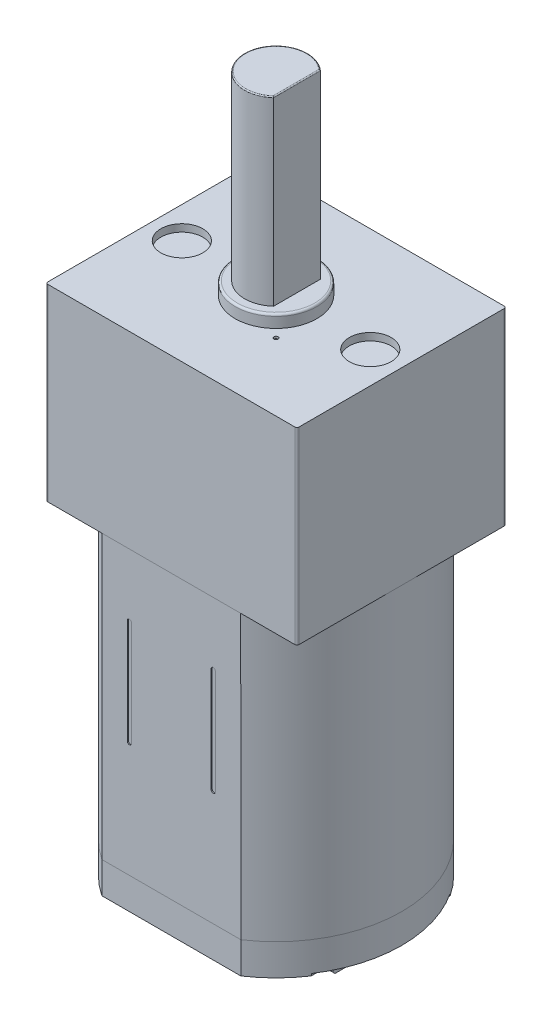
from build123d import *

# Parameters (mm, degrees)
EXTRUDE_1_DEPTH     = 13.5
SKETCH_2_W          = 12
SKETCH_2_H          = 10
EXTRUDE_2_DEPTH     = 9
SKETCH_3_R          = 1.95
EXTRUDE_3_DEPTH     = 0.6
EXTRUDE_4_DEPTH     = 8.67
SKETCH_5_R          = 1
CUT_EXTRUDE_1_DEPTH = 0.35
FILLET_1_R          = 0.1
EXTRUDE_6_DEPTH     = 1.4
EXTRUDE_7_DEPTH     = 0.1
SKETCH_8_W          = 0.3
SKETCH_8_H          = 1.5
EXTRUDE_8_DEPTH     = 2
CHAMFER_1_SIZE      = 0.1
SKETCH_9_R          = 0.4
CUT_EXTRUDE_2_DEPTH = 7
SKETCH_10_R         = 2.5
EXTRUDE_9_DEPTH     = 2
FILLET_2_R          = 0.2
SKETCH_11_R         = 0.1
CUT_EXTRUDE_3_DEPTH = 0.7
FILLET_3_R          = 0.1
CUT_EXTRUDE_4_DEPTH = 0.05
FILLET_4_R          = 0.05
FILLET_5_R          = 0.1


with BuildPart() as part:
    # Эскиз1 → Бобышка-Вытянуть1 (new body)
    with BuildSketch(Plane(origin=(0, 0, 0), x_dir=(1, 0, 0), z_dir=(0, 1, 0))):
        with BuildLine():
            Line((-3.31662479, 5), (3.31662479, 5))
            ThreePointArc((3.31662479, 5), (6, 0), (3.31662479, -5))
            Line((3.31662479, -5), (-3.31662479, -5))
            ThreePointArc((-3.31662479, -5), (-6, 0), (-3.31662479, 5))
        make_face()
    extrude(amount=EXTRUDE_1_DEPTH)

    # Эскиз2 → Бобышка-Вытянуть2 (add)
    with BuildSketch(Plane(origin=(0, 13.5, 0), x_dir=(1, 0, 0), z_dir=(0, 1, 0))):
        with Locations((0, -0.001677367)):
            Rectangle(SKETCH_2_W, SKETCH_2_H)
    extrude(amount=EXTRUDE_2_DEPTH)

    # Эскиз3 → Бобышка-Вытянуть3 (add)
    with BuildSketch(Plane(origin=(0, 22.5, 0), x_dir=(1, 0, 0), z_dir=(0, 1, 0))):
        with Locations(Location((0, 0, 0), (0, 0, 270))):
            Circle(SKETCH_3_R)
    extrude(amount=EXTRUDE_3_DEPTH)

    # Эскиз4 → Бобышка-Вытянуть4 (add)
    with BuildSketch(Plane(origin=(0, 23.1, 0), x_dir=(1, 0, 0), z_dir=(0, 1, 0))):
        with BuildLine():
            Line((1, 1.118033989), (1, -1.118033989))
            ThreePointArc((1, -1.118033989), (-1.5, 0), (1, 1.118033989))
        make_face()
    extrude(amount=EXTRUDE_4_DEPTH)

    # Эскиз5 → Вырез-Вытянуть1 (cut)
    with BuildSketch(Plane(origin=(0, 22.5, 0), x_dir=(1, 0, 0), z_dir=(0, 1, 0))):
        with Locations(Location((-4.5, 0, 0), (0, 0, 270))):
            Circle(SKETCH_5_R)
        with Locations(Location((4.5, 0, 0), (0, 0, 90))):
            Circle(SKETCH_5_R)
    extrude(amount=-CUT_EXTRUDE_1_DEPTH, mode=Mode.SUBTRACT)

    # Скругление1
    fillet_1_edges = [part.edges().sort_by_distance(p)[0] for p in [
        (-6, 18, 5.001677367),
        (6, 18, 5.001677367),
        (6, 18, -4.998322633),
        (-6, 18, -4.998322633),
    ]]
    fillet(fillet_1_edges, radius=FILLET_1_R)

    # Эскиз11 → Вырез-Вытянуть3 (cut)
    with BuildSketch(Plane(origin=(0, 23.1, 0), x_dir=(1, 0, 0), z_dir=(0, 1, 0))):
        with Locations(Location((1.767766953, -1.767766953, 0), (0, 0, 270))):
            Circle(SKETCH_11_R)
        with Locations(Location((-1.767766953, 1.767766953, 0), (0, 0, 270))):
            Circle(SKETCH_11_R)
    extrude(amount=-CUT_EXTRUDE_3_DEPTH, mode=Mode.SUBTRACT)

    # Эскиз12 → Вырез-Вытянуть4 (cut)
    with BuildSketch(Plane(origin=(0, 0, -5), x_dir=(-1, 0, 0), z_dir=(0, 0, -1))):
        with BuildLine():
            Line((1.9, 5.5), (1.9, 10.5))
            ThreePointArc((1.9, 10.5), (2, 10.6), (2.1, 10.5))
            Line((2.1, 10.5), (2.1, 5.5))
            ThreePointArc((2.1, 5.5), (2, 5.4), (1.9, 5.5))
        make_face()
        with BuildLine():
            Line((-2.1, 5.5), (-2.1, 10.5))
            ThreePointArc((-2.1, 10.5), (-2, 10.6), (-1.9, 10.5))
            Line((-1.9, 10.5), (-1.9, 5.5))
            ThreePointArc((-1.9, 5.5), (-2, 5.4), (-2.1, 5.5))
        make_face()
    cut_extrude_4 = extrude(amount=-CUT_EXTRUDE_4_DEPTH, mode=Mode.SUBTRACT)

    # Зеркальное отражение1: Вырез-Вытянуть4 across plane
    add(cut_extrude_4.mirror(Plane(origin=(0, 0, 0), x_dir=(1, 0, 0), z_dir=(0, 0, -1))), mode=Mode.SUBTRACT)

    # Скругление4
    fillet_4_edges = [part.edges().sort_by_distance(p)[0] for p in [
        (-1.5, 31.77, 0),
        (1, 31.77, 0),
    ]]
    fillet(fillet_4_edges, radius=FILLET_4_R)

    # Скругление5
    fillet_5_edges = [part.edges().sort_by_distance(p)[0] for p in [
        (0, 23.1, -1.95),
    ]]
    fillet(fillet_5_edges, radius=FILLET_5_R)


with BuildPart() as body_2:
    # Эскиз6 → Бобышка-Вытянуть6 (new body)
    with BuildSketch(Plane.XZ):
        with BuildLine():
            Line((-3.31662479, -5), (3.31662479, -5))
            ThreePointArc((3.31662479, -5), (6, 0), (3.31662479, 5))
            Line((3.31662479, 5), (-3.31662479, 5))
            ThreePointArc((-3.31662479, 5), (-6, 0), (-3.31662479, -5))
        make_face()
    extrude(amount=EXTRUDE_6_DEPTH)

    # Эскиз7 → Бобышка-Вытянуть7 (add)
    with BuildSketch(Plane(origin=(0, -1.4, 0), x_dir=(-1, 0, 0), z_dir=(0, -1, 0))):
        with BuildLine():
            ThreePointArc((3.31662479, -5), (4.242640687, -4.242640687), (5, -3.31662479))
            Line((5, -3.31662479), (5, 3.31662479))
            ThreePointArc((5, 3.31662479), (4.242640687, 4.242640687), (3.31662479, 5))
            Line((3.31662479, 5), (-3.31662479, 5))
            ThreePointArc((-3.31662479, 5), (-4.242640687, 4.242640687), (-5, 3.31662479))
            Line((-5, 3.31662479), (-5, -3.31662479))
            ThreePointArc((-5, -3.31662479), (-4.242640687, -4.242640687), (-3.31662479, -5))
            Line((-3.31662479, -5), (3.31662479, -5))
        make_face()
    extrude(amount=EXTRUDE_7_DEPTH)

    # Эскиз8 → Бобышка-Вытянуть8 (add)
    with BuildSketch(Plane(origin=(0, -1.5, 0), x_dir=(-1, 0, 0), z_dir=(0, -1, 0))):
        with Locations((3.315, 0)):
            Rectangle(SKETCH_8_W, SKETCH_8_H)
        with Locations((-3.315, 0)):
            Rectangle(SKETCH_8_W, SKETCH_8_H)
    extrude(amount=EXTRUDE_8_DEPTH)

    # Фаска1
    chamfer_1_edges = [body_2.edges().sort_by_distance(p)[0] for p in [
        (-3.315, -3.5, -0.75),
        (-3.315, -3.5, 0.75),
        (3.315, -3.5, 0.75),
        (3.315, -3.5, -0.75),
    ]]
    chamfer(chamfer_1_edges, length=CHAMFER_1_SIZE)

    # Эскиз9 → Вырез-Вытянуть2 (cut)
    with BuildSketch(Plane.ZY.offset(3.465)):
        with Locations((0, -2.5)):
            Circle(SKETCH_9_R)
    extrude(amount=-CUT_EXTRUDE_2_DEPTH, mode=Mode.SUBTRACT)

    # Эскиз10 → Бобышка-Вытянуть9 (add)
    with BuildSketch(Plane(origin=(0, -1.5, 0), x_dir=(-1, 0, 0), z_dir=(0, -1, 0))):
        with Locations(Location((0, 0, 0), (0, 0, 90))):
            Circle(SKETCH_10_R)
    extrude(amount=EXTRUDE_9_DEPTH)

    # Скругление2
    fillet_2_edges = [body_2.edges().sort_by_distance(p)[0] for p in [
        (0, -3.5, 2.5),
    ]]
    fillet(fillet_2_edges, radius=FILLET_2_R)

    # Скругление3
    fillet_3_edges = [body_2.edges().sort_by_distance(p)[0] for p in [
        (0, -1.5, 2.5),
    ]]
    fillet(fillet_3_edges, radius=FILLET_3_R)


solid = Compound([part.part, body_2.part])
